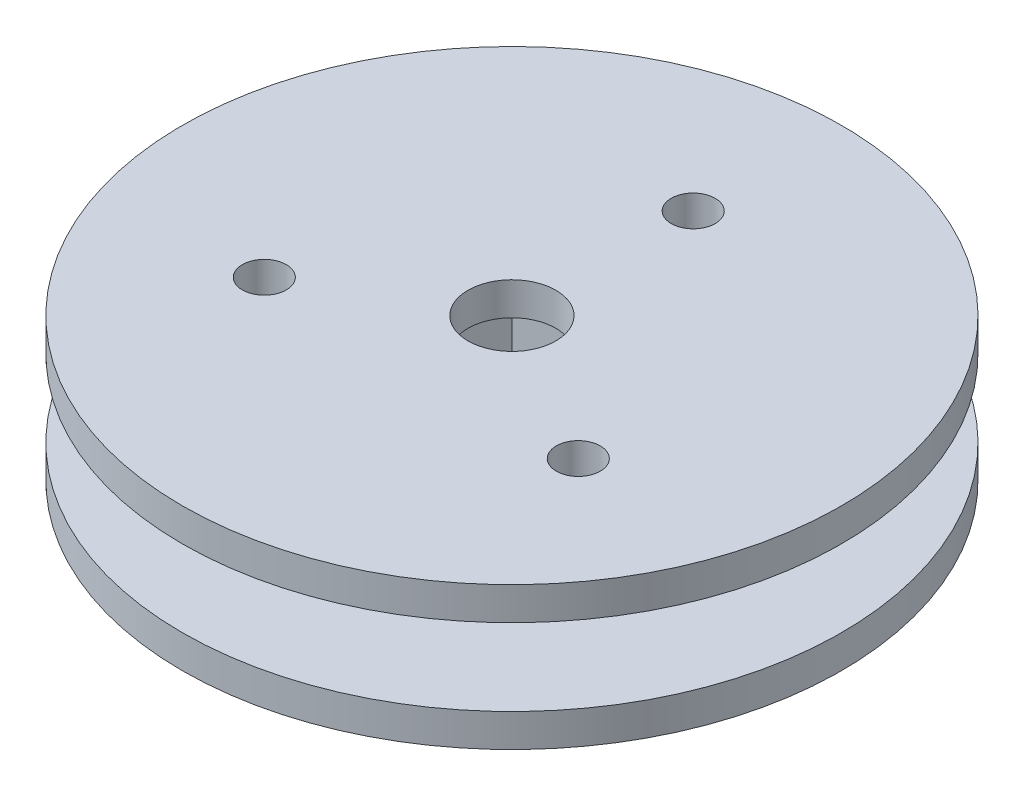
from build123d import *

# Parameters (mm, degrees)
SKETCH_1_R          = 15
EXTRUDE_1_DEPTH     = 1.5
SKETCH_2_R          = 6
SKETCH_2_W          = 7.5
SKETCH_2_H          = 7.5
EXTRUDE_2_DEPTH     = 3.5
SKETCH_3_W          = 7.5
SKETCH_3_H          = 7.5
CUT_EXTRUDE_1_DEPTH = 3.5
SKETCH_4_R          = 15
EXTRUDE_3_DEPTH     = 1.5
SKETCH_5_R          = 2
CUT_EXTRUDE_2_DEPTH = 1.5
SKETCH_6_R          = 1
CUT_EXTRUDE_3_DEPTH = 10


with BuildPart() as part:
    # 草图1 → 凸台-拉伸1 (new body)
    with BuildSketch(Plane(origin=(0, 0, 0), x_dir=(1, 0, 0), z_dir=(0, 1, 0))):
        Circle(SKETCH_1_R)
    extrude(amount=EXTRUDE_1_DEPTH)

    # 草图2 → 凸台-拉伸2 (add)
    with BuildSketch(Plane(origin=(0, 1.5, 0), x_dir=(1, 0, 0), z_dir=(0, 1, 0))):
        Circle(SKETCH_2_R)
        Rectangle(SKETCH_2_W, SKETCH_2_H, mode=Mode.SUBTRACT)
    extrude(amount=EXTRUDE_2_DEPTH)

    # 草图3 → 切除-拉伸1 (cut)
    with BuildSketch(Plane(origin=(0, 1.5, 0), x_dir=(1, 0, 0), z_dir=(0, 1, 0))):
        Rectangle(SKETCH_3_W, SKETCH_3_H)
    extrude(amount=-CUT_EXTRUDE_1_DEPTH, mode=Mode.SUBTRACT)

    # 草图4 → 凸台-拉伸3 (add)
    with BuildSketch(Plane(origin=(0, 5, 0), x_dir=(1, 0, 0), z_dir=(0, 1, 0))):
        Circle(SKETCH_4_R)
    extrude(amount=EXTRUDE_3_DEPTH)

    # 草图5 → 切除-拉伸2 (cut)
    with BuildSketch(Plane(origin=(0, 6.5, 0), x_dir=(1, 0, 0), z_dir=(0, 1, 0))):
        Circle(SKETCH_5_R)
    extrude(amount=-CUT_EXTRUDE_2_DEPTH, mode=Mode.SUBTRACT)

    # 草图6 → 切除-拉伸3 (cut)
    with BuildSketch(Plane(origin=(0, 6.5, 0), x_dir=(1, 0, 0), z_dir=(0, 1, 0))):
        with Locations((0, 8.25)):
            Circle(SKETCH_6_R)
        with Locations((-7.144709581, -4.125)):
            Circle(SKETCH_6_R)
        with Locations((7.144709581, -4.125)):
            Circle(SKETCH_6_R)
    extrude(amount=-CUT_EXTRUDE_3_DEPTH, mode=Mode.SUBTRACT)


solid = part.part
